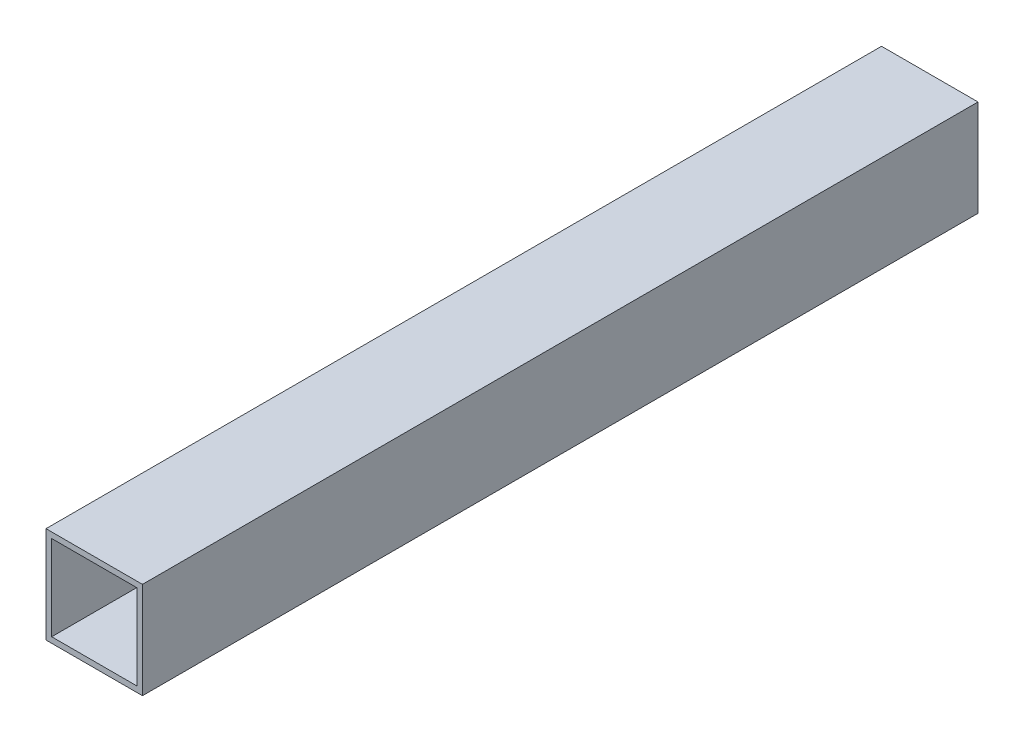
from build123d import *

# Parameters (mm, degrees)
SKETCH1_W           = 25.4
SKETCH1_H           = 25.4
SKETCH1_W_2         = 22.4
SKETCH1_H_2         = 22.4
BOSS_EXTRUDE1_DEPTH = 220


with BuildPart() as part:
    # Sketch1 → Boss-Extrude1 (new body)
    with BuildSketch(Plane.XY):
        Rectangle(SKETCH1_W, SKETCH1_H)
        Rectangle(SKETCH1_W_2, SKETCH1_H_2, mode=Mode.SUBTRACT)
    extrude(amount=BOSS_EXTRUDE1_DEPTH)


solid = part.part
